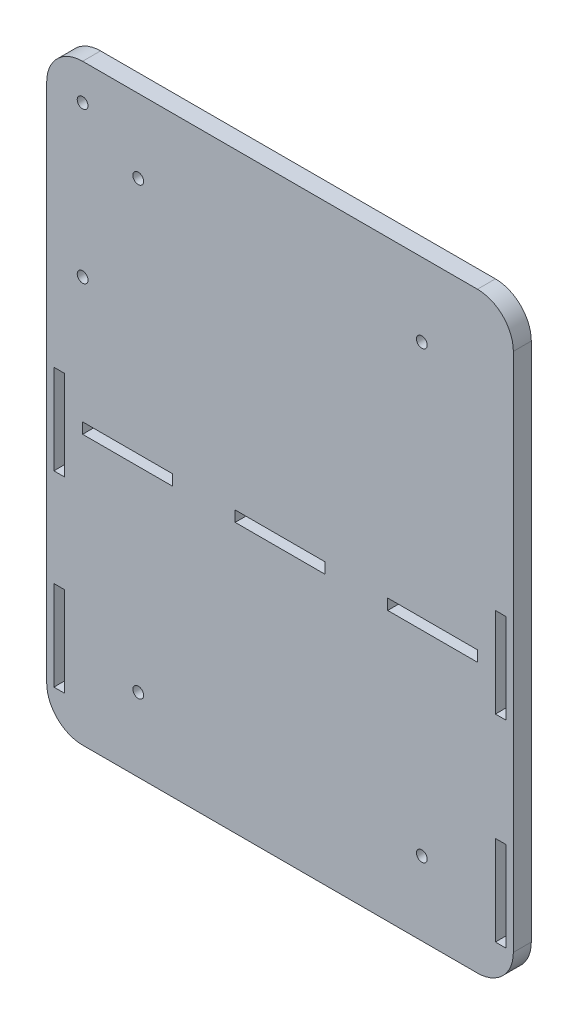
from build123d import *

# Parameters (mm, degrees)
RESSALTO_EXTRUS_O1_DEPTH = 5
ESBO_O2_R                = 1.5
CORTE_EXTRUS_O1_DEPTH    = 5
ESBO_O3_R                = 1.5
CORTE_EXTRUS_O2_DEPTH    = 6
ESBO_O6_W                = 3
ESBO_O6_H                = 25
ESBO_O6_W_2              = 25
ESBO_O6_H_2              = 3
CORTE_EXTRUS_O4_DEPTH    = 6


with BuildPart() as part:
    # Esboço1 → Ressalto-extrusão1 (new body)
    with BuildSketch(Plane.XY):
        with BuildLine():
            Line((-49.217119449, -36.393854661), (60.782880551, -36.393854661))
            ThreePointArc((60.782880551, -36.393854661), (67.853948363, -33.464922473), (70.782880551, -26.393854661))
            Line((70.782880551, -26.393854661), (70.782880551, 118.606145339))
            ThreePointArc((70.782880551, 118.606145339), (67.853948363, 125.67721315), (60.782880551, 128.606145339))
            Line((60.782880551, 128.606145339), (-49.217119449, 128.606145339))
            ThreePointArc((-49.217119449, 128.606145339), (-56.288187261, 125.67721315), (-59.217119449, 118.606145339))
            Line((-59.217119449, 118.606145339), (-59.217119449, -26.393854661))
            ThreePointArc((-59.217119449, -26.393854661), (-56.288187261, -33.464922473), (-49.217119449, -36.393854661))
        make_face()
    extrude(amount=RESSALTO_EXTRUS_O1_DEPTH)

    # Esboço2 → Corte-extrusão1 (cut)
    with BuildSketch(Plane(origin=(0, 0, 0), x_dir=(-1, 0, 0), z_dir=(0, 0, -1))):
        with Locations((33.717119449, -15.893854661)):
            Circle(ESBO_O2_R)
        with Locations((33.717119449, 108.106145339)):
            Circle(ESBO_O2_R)
        with Locations((-45.282880551, -15.893854661)):
            Circle(ESBO_O2_R)
        with Locations((-45.282880551, 108.106145339)):
            Circle(ESBO_O2_R)
    extrude(amount=-CORTE_EXTRUS_O1_DEPTH, mode=Mode.SUBTRACT)

    # Esboço3 → Corte-extrusão2 (cut, through all)
    with BuildSketch(Plane(origin=(0, 0, 0), x_dir=(-1, 0, 0), z_dir=(0, 0, -1))):
        with Locations((49.217119449, 118.606145339)):
            Circle(ESBO_O3_R)
        with Locations((49.217119449, 76.556145339)):
            Circle(ESBO_O3_R)
    extrude(amount=-CORTE_EXTRUS_O2_DEPTH, mode=Mode.SUBTRACT)

    # Esboço6 → Corte-extrusão4 (cut, through all)
    with BuildSketch(Plane(origin=(0, 0, 0), x_dir=(-1, 0, 0), z_dir=(0, 0, -1))):
        with Locations((-67.282880551, -13.893854661)):
            Rectangle(ESBO_O6_W, ESBO_O6_H)
        with Locations((-67.282880551, 41.106145339)):
            Rectangle(ESBO_O6_W, ESBO_O6_H)
        with Locations((-48.282880551, 40.106145339)):
            Rectangle(ESBO_O6_W_2, ESBO_O6_H_2)
        with Locations((36.717119449, 40.106145339)):
            Rectangle(ESBO_O6_W_2, ESBO_O6_H_2)
        with Locations((55.717119449, 38.28693606)):
            Rectangle(ESBO_O6_W, ESBO_O6_H)
        with Locations((55.717119449, -13.893854661)):
            Rectangle(ESBO_O6_W, ESBO_O6_H)
        with Locations((-5.782880551, 40.106145339)):
            Rectangle(ESBO_O6_W_2, ESBO_O6_H_2)
    extrude(amount=-CORTE_EXTRUS_O4_DEPTH, mode=Mode.SUBTRACT)


solid = part.part
